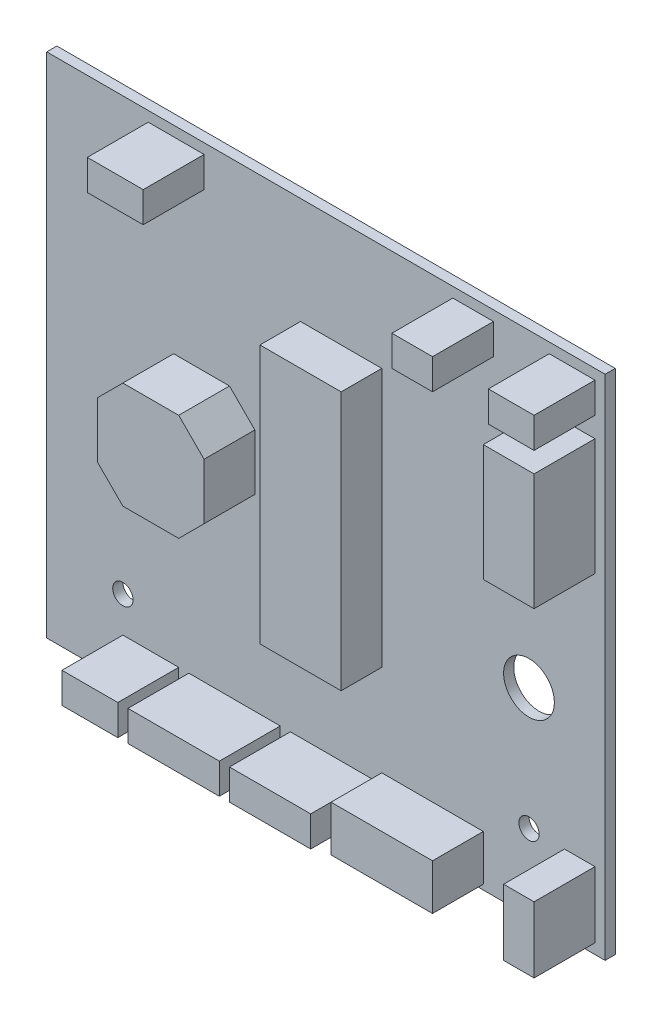
from build123d import *

# Parameters (mm, degrees)
ESQUISSE1_W             = 110
ESQUISSE1_H             = 100
EXTRUSION1_DEPTH        = 2
ESQUISSE2_R             = 5
ESQUISSE2_R_2           = 2
ENL_V_MAT_EXTRU_1_DEPTH = 10
ESQUISSE3_W             = 11
ESQUISSE3_H             = 6
ESQUISSE3_W_2           = 18
ESQUISSE3_W_3           = 16
ESQUISSE3_W_4           = 6
ESQUISSE3_H_2           = 13
ESQUISSE3_W_5           = 9
ESQUISSE3_W_6           = 8
ESQUISSE3_W_7           = 20
ESQUISSE3_H_3           = 9
ESQUISSE3_H_4           = 51
ESQUISSE3_W_8           = 21
ESQUISSE3_H_5           = 21
ESQUISSE3_W_9           = 10
ESQUISSE3_H_6           = 23
EXTRUSION2_DEPTH        = 12
ESQUISSE4_W             = 21
ESQUISSE4_H             = 21
ESQUISSE4_W_2           = 20
ESQUISSE4_H_2           = 9
ENL_V_MAT_EXTRU_2_DEPTH = 2
ESQUISSE5_W             = 16
ESQUISSE5_H             = 51
ENL_V_MAT_EXTRU_3_DEPTH = 4
CHANFREIN1_SIZE         = 5


with BuildPart() as part:
    # Esquisse1 → Extrusion1 (new body)
    with BuildSketch(Plane.XY):
        with Locations((-55, 50)):
            Rectangle(ESQUISSE1_W, ESQUISSE1_H)
    extrude(amount=EXTRUSION1_DEPTH)

    # Esquisse2 → Enlèv. mat.-Extru.1 (cut)
    with BuildSketch(Plane.XY.offset(2)):
        with Locations((-15, 39)):
            Circle(ESQUISSE2_R)
        with Locations((-15, 15)):
            Circle(ESQUISSE2_R_2)
        with Locations((-15, 85)):
            Circle(ESQUISSE2_R_2)
        with Locations((-95, 15)):
            Circle(ESQUISSE2_R_2)
        with Locations((-95, 85)):
            Circle(ESQUISSE2_R_2)
    extrude(amount=-ENL_V_MAT_EXTRU_1_DEPTH, mode=Mode.SUBTRACT)

    # Esquisse3 → Extrusion2 (add)
    with BuildSketch(Plane.XY.offset(2)):
        with Locations((-89.5, 5)):
            Rectangle(ESQUISSE3_W, ESQUISSE3_H)
        with Locations((-73, 5)):
            Rectangle(ESQUISSE3_W_2, ESQUISSE3_H)
        with Locations((-54, 5)):
            Rectangle(ESQUISSE3_W_3, ESQUISSE3_H)
        with Locations((-5, 8.5)):
            Rectangle(ESQUISSE3_W_4, ESQUISSE3_H_2)
        with Locations((-6.5, 95)):
            Rectangle(ESQUISSE3_W_5, ESQUISSE3_H)
        with Locations((-26, 95)):
            Rectangle(ESQUISSE3_W_6, ESQUISSE3_H)
        with Locations((-84.5, 95)):
            Rectangle(ESQUISSE3_W, ESQUISSE3_H)
        with Locations((-34, 5.5)):
            Rectangle(ESQUISSE3_W_7, ESQUISSE3_H_3)
        with Locations((-52, 53.5)):
            Rectangle(ESQUISSE3_W_3, ESQUISSE3_H_4)
        with Locations((-79.5, 50.5)):
            Rectangle(ESQUISSE3_W_8, ESQUISSE3_H_5)
        with Locations((-7, 76.5)):
            Rectangle(ESQUISSE3_W_9, ESQUISSE3_H_6)
    extrude(amount=EXTRUSION2_DEPTH)

    # Esquisse4 → Enlèv. mat.-Extru.2 (cut)
    with BuildSketch(Plane.XY.offset(14)):
        with Locations((-79.5, 50.5)):
            Rectangle(ESQUISSE4_W, ESQUISSE4_H)
        with Locations((-34, 5.5)):
            Rectangle(ESQUISSE4_W_2, ESQUISSE4_H_2)
    extrude(amount=-ENL_V_MAT_EXTRU_2_DEPTH, mode=Mode.SUBTRACT)

    # Esquisse5 → Enlèv. mat.-Extru.3 (cut)
    with BuildSketch(Plane.XY.offset(14)):
        with Locations((-52, 53.5)):
            Rectangle(ESQUISSE5_W, ESQUISSE5_H)
    extrude(amount=-ENL_V_MAT_EXTRU_3_DEPTH, mode=Mode.SUBTRACT)

    # Chanfrein1
    chanfrein1_edges = [part.edges().sort_by_distance(p)[0] for p in [
        (-90, 40, 7),
        (-90, 61, 7),
        (-69, 61, 7),
        (-69, 40, 7),
    ]]
    chamfer(chanfrein1_edges, length=CHANFREIN1_SIZE)


solid = part.part
